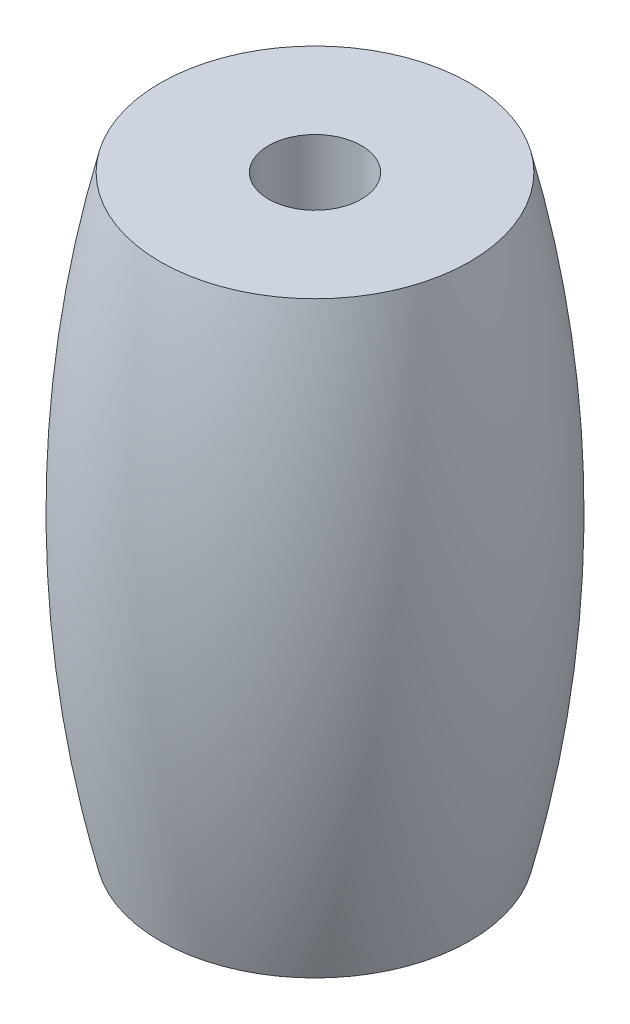
from build123d import *


with BuildPart() as part:
    # 草图1 → 旋转1 (revolve)
    with BuildSketch(Plane.XY):
        with BuildLine():
            Line((-1.5, 14.825471698), (-1.5, -4.174528302))
            Line((-1.5, -4.174528302), (-5, -4.174528302))
            ThreePointArc((-5, -4.174528302), (-6.144498459, 5.325471698), (-5, 14.825471698))
            Line((-5, 14.825471698), (-1.5, 14.825471698))
        make_face()
    revolve(axis=Axis((0, 17.097948658, 0), (0, -1, 0)))


solid = part.part
